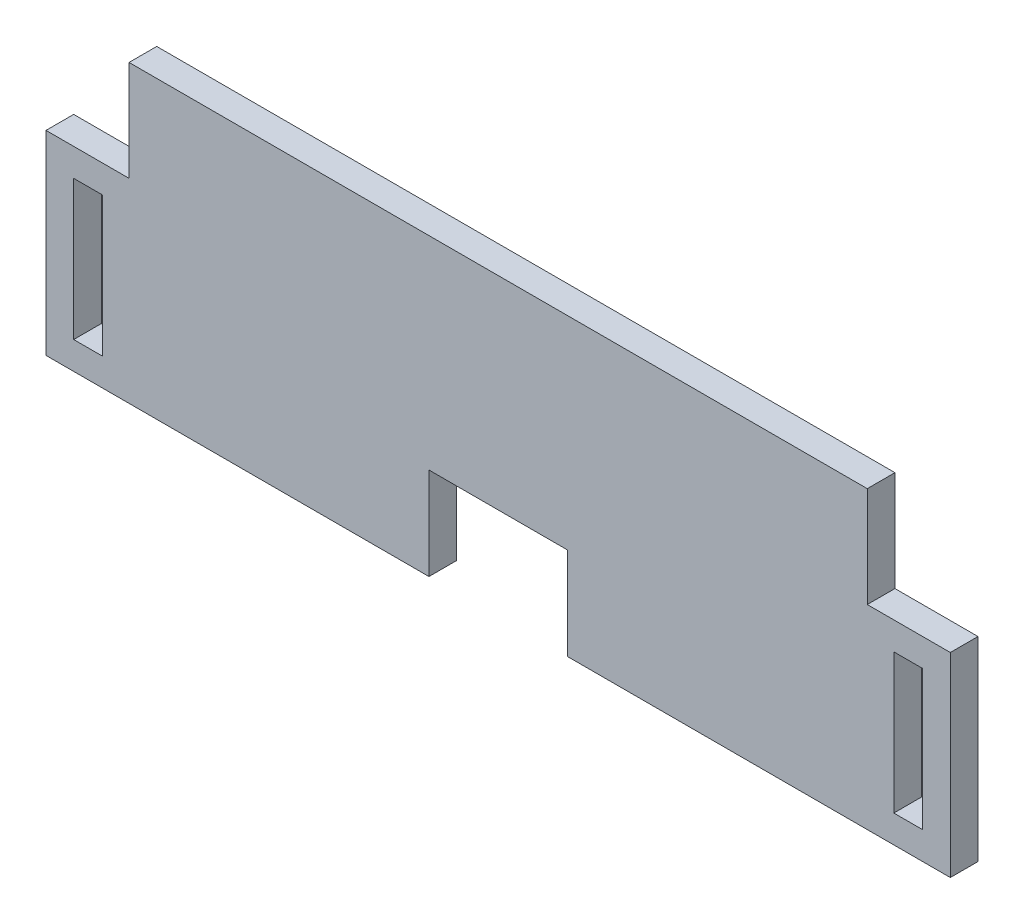
from build123d import *

# Parameters (mm, degrees)
CROQUIS1_W              = 3.123
CROQUIS1_H              = 15.13
SALIENTE_EXTRUIR1_DEPTH = 3
CROQUIS2_W              = 15
CROQUIS2_H              = 10
CORTAR_EXTRUIR1_DEPTH   = 4


with BuildPart() as part:
    # Croquis1 → Saliente-Extruir1 (new body)
    with BuildSketch(Plane.XY):
        Polygon((-49, 0), (49, 0), (49, 21.123), (40, 21.123), (40, 32), (-40, 32), (-40, 21.123), (-49, 21.123), align=None)
        with Locations((-44.4385, 10.558)):
            Rectangle(CROQUIS1_W, CROQUIS1_H, mode=Mode.SUBTRACT)
        with Locations((44.4385, 10.558)):
            Rectangle(CROQUIS1_W, CROQUIS1_H, mode=Mode.SUBTRACT)
    extrude(amount=SALIENTE_EXTRUIR1_DEPTH)

    # Croquis2 → Cortar-Extruir1 (cut, through all)
    with BuildSketch(Plane.XY.offset(3)):
        with Locations((0, 5)):
            Rectangle(CROQUIS2_W, CROQUIS2_H)
    extrude(amount=-CORTAR_EXTRUIR1_DEPTH, mode=Mode.SUBTRACT)


solid = part.part
